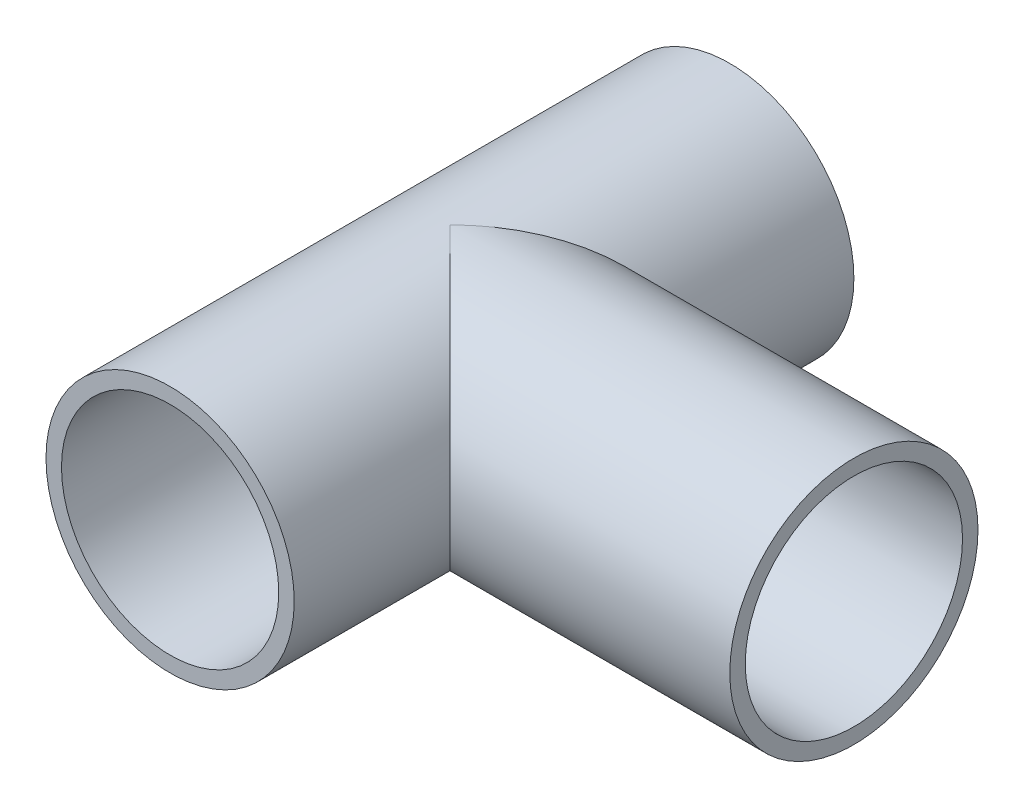
from build123d import *

# Parameters (mm, degrees)
THROUGH_SECTION_R                   = 161.925
THROUGH_SECTION_R_2                 = 141.732
THROUGH_SECTION_EXTRUDE_DEPTH       = 365.125
ORTHOGONAL_SECTION_OD_EXTRUDE_REACH = 690.975
ORTHOGONAL_SECTION_OD_R             = 161.925
ORTHOGONAL_SECTION_ID_CUT_REACH     = 690.975
ORTHOGONAL_SECTION_ID_R             = 141.732


with BuildPart() as part:
    # Through Section → Through Section Extrude (new body, symmetric)
    with BuildSketch(Plane.XY):
        Circle(THROUGH_SECTION_R)
        Circle(THROUGH_SECTION_R_2, mode=Mode.SUBTRACT)
    extrude(amount=THROUGH_SECTION_EXTRUDE_DEPTH, both=True)

    # Orthogonal Section OD → Orthogonal Section OD Extrude (add, up to next)
    with BuildSketch(Plane(origin=(527.05, 0, 0), x_dir=(0, 0, -1), z_dir=(1, 0, 0)), mode=Mode.PRIVATE) as orthogonal_section_od_extrude_sk1:
        Circle(ORTHOGONAL_SECTION_OD_R)
    orthogonal_section_od_extrude_tool1 = extrude(orthogonal_section_od_extrude_sk1.sketch, amount=-ORTHOGONAL_SECTION_OD_EXTRUDE_REACH, mode=Mode.PRIVATE) - part.part
    add(orthogonal_section_od_extrude_tool1.solids().sort_by_distance((527.05, 0, 0))[0])

    # Orthogonal Section ID → Orthogonal Section ID Cut (cut, up to next)
    with BuildSketch(Plane(origin=(527.05, 0, 0), x_dir=(0, 0, -1), z_dir=(1, 0, 0)), mode=Mode.PRIVATE) as orthogonal_section_id_cut_sk1:
        Circle(ORTHOGONAL_SECTION_ID_R)
    orthogonal_section_id_cut_tool1 = extrude(orthogonal_section_id_cut_sk1.sketch, amount=-ORTHOGONAL_SECTION_ID_CUT_REACH, mode=Mode.PRIVATE) & part.part
    add(orthogonal_section_id_cut_tool1.solids().sort_by_distance((527.05, 0, 0))[0], mode=Mode.SUBTRACT)


solid = part.part
